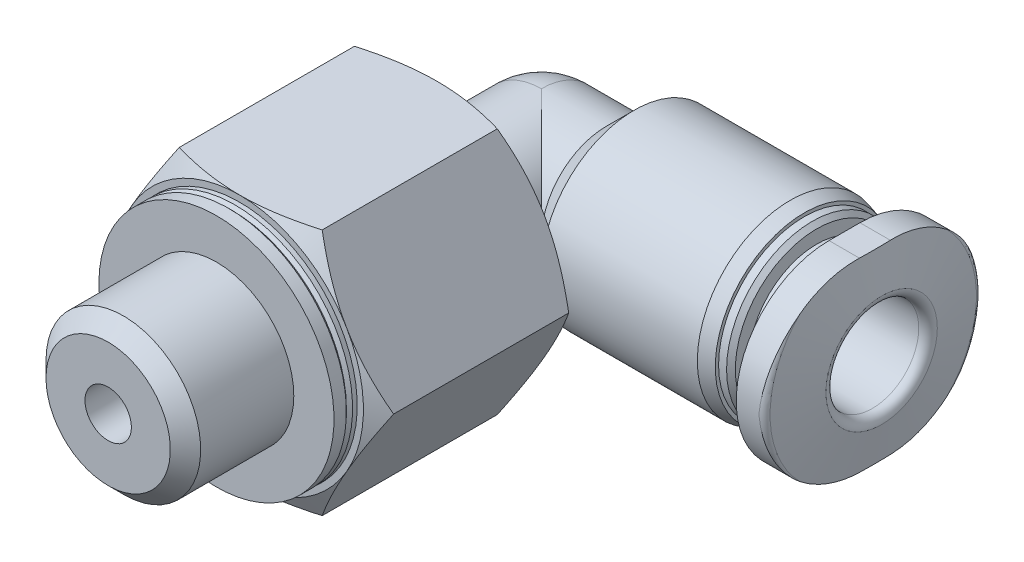
from build123d import *
from build123d.topology import SkipClean

# Parameters (mm, degrees)
LINEAR_AUSTRAGEN1_DEPTH = 1.2
SKIZZE6_W               = 14
SKIZZE6_H               = 0.75
SKIZZE7_W               = 16
SKIZZE7_H               = 16
LINEAR_AUSTRAGEN2_DEPTH = 7.166666667


with BuildPart() as part:
    # Skizze1 → Rotation1 (revolve)
    with BuildSketch(Plane.XY):
        with BuildLine():
            Line((0, 2.1), (2.1, 2.1))
            Line((2.1, 2.1), (3, 3))
            Line((3, 3), (8.042857143, 3))
            Line((8.042857143, 3), (8.5, 2.877508941))
            Line((8.5, 2.877508941), (8.5, 2.770329264))
            Line((8.5, 2.770329264), (8.758578644, 2.770329264))
            Line((8.758578644, 2.770329264), (8.9, 2.628907907))
            Line((8.9, 2.628907907), (8.9, 2.2))
            Line((8.9, 2.2), (9.43, 2.2))
            ThreePointArc((9.43, 2.2), (9.691629509, 2.308370491), (9.8, 2.57))
            Line((9.8, 2.57), (9.8, 3.5))
            Line((9.8, 3.5), (10.532424207, 3.5))
            ThreePointArc((10.532424207, 3.5), (10.660981728, 3.453208889), (10.729385757, 3.334729636))
            Line((10.729385757, 3.334729636), (11, 1.8))
            Line((11, 1.8), (11, 0))
            Line((11, 0), (-2.1, 0))
            ThreePointArc((-2.1, 0), (-1.48492424, 1.48492424), (0, 2.1))
        make_face()
    revolve(axis=Axis((11, 0, 0), (-1, 0, 0)))

    # Skizze2 → Rotation2 (revolve)
    with SkipClean():  # the faces are left unmerged after this step: merging them gives an invalid solid
        with BuildSketch(Plane(origin=(0, 0, 0), x_dir=(0, 0, -1), z_dir=(1, 0, 0))):
            Polygon((-10.5, 0), (-10.5, 3.8), (-10.1, 3.8), (-10, 3.7), (-9.9, 3.8), (-9.75, 3.8), (-9.75, 4), (-9.380495828, 4.64), (-3.744504172, 4.64), (-3.375, 4), (-3.375, 2.25), (-2.8, 2.25), (-2.65, 2.1), (0, 2.1), (0, 0), align=None)
        revolve(axis=Axis((0, 0, 0), (0, 0, 1)))

    # Skizze3 → Rotation3 (revolve)
    with SkipClean():  # the faces are left unmerged after this step: merging them gives an invalid solid
        with BuildSketch(Plane(origin=(0, 0, 0), x_dir=(0, 0, -1), z_dir=(1, 0, 0))):
            Polygon((-14, 0), (-14, 2.0095), (-13.5095, 2.5), (-10.5, 2.5), (-10.5, 0), align=None)
        revolve(axis=Axis((0, 0, 10.5), (0, 0, 1)))

    # Skizze4 → Linear austragen1 (cut)
    with SkipClean():  # the faces are left unmerged after this step: merging them gives an invalid solid
        with BuildSketch(Plane(origin=(11, 0, 0), x_dir=(0, 0, -1), z_dir=(1, 0, 0))):
            Polygon((-4.2, 2.424871131), (-4.2, -2.424871131), (0, -4.849742261), (4.2, -2.424871131), (4.2, 2.424871131), (0, 4.849742261), align=None)
            with BuildLine():
                Line((-0.5, -3), (0.5, -3))
                ThreePointArc((0.5, -3), (2.621320344, -2.121320344), (3.5, 0))
                ThreePointArc((3.5, 0), (2.621320344, 2.121320344), (0.5, 3))
                Line((0.5, 3), (-0.5, 3))
                ThreePointArc((-0.5, 3), (-2.621320344, 2.121320344), (-3.5, 0))
                ThreePointArc((-3.5, 0), (-2.621320344, -2.121320344), (-0.5, -3))
            make_face(mode=Mode.SUBTRACT)
        extrude(amount=-LINEAR_AUSTRAGEN1_DEPTH, mode=Mode.SUBTRACT)

    # Skizze6 → Schnitt-Rotation1 (revolve, cut)
    with SkipClean():  # the faces are left unmerged after this step: merging them gives an invalid solid
        with BuildSketch(Plane(origin=(0, 0, 0), x_dir=(0, 0, -1), z_dir=(1, 0, 0))):
            with Locations((-7, 0.375)):
                Rectangle(SKIZZE6_W, SKIZZE6_H)
        revolve(axis=Axis((0, 0, 0), (0, 0, 1)), mode=Mode.SUBTRACT)

    # Skizze5 → Schnitt-Rotation2 (revolve, cut)
    with SkipClean():  # the faces are left unmerged after this step: merging them gives an invalid solid
        with BuildSketch(Plane(origin=(0, 0, 0), x_dir=(1, 0, 0), z_dir=(0, 1, 0))):
            with BuildLine():
                Line((0, 0.75), (1.5, 0.75))
                Line((1.5, 0.75), (1.5, 1.5))
                Line((1.5, 1.5), (10.7, 1.5))
                ThreePointArc((10.7, 1.5), (10.912132034, 1.587867966), (11, 1.8))
                Line((11, 1.8), (11, 0))
                Line((11, 0), (-0.75, 0))
                ThreePointArc((-0.75, 0), (-0.530330086, 0.530330086), (0, 0.75))
            make_face()
        revolve(axis=Axis((11, 0, 0), (-1, 0, 0)), mode=Mode.SUBTRACT)

    # Skizze7 → Linear austragen2 (cut)
    with SkipClean():  # the faces are left unmerged after this step: merging them gives an invalid solid
        with BuildSketch(Plane.XY.offset(10.5)):
            Rectangle(SKIZZE7_W, SKIZZE7_H)
            Polygon((-4.618802154, 0), (-2.309401077, -4), (2.309401077, -4), (4.618802154, 0), (2.309401077, 4), (-2.309401077, 4), align=None, mode=Mode.SUBTRACT)
        extrude(amount=-LINEAR_AUSTRAGEN2_DEPTH, mode=Mode.SUBTRACT)


solid = part.part
